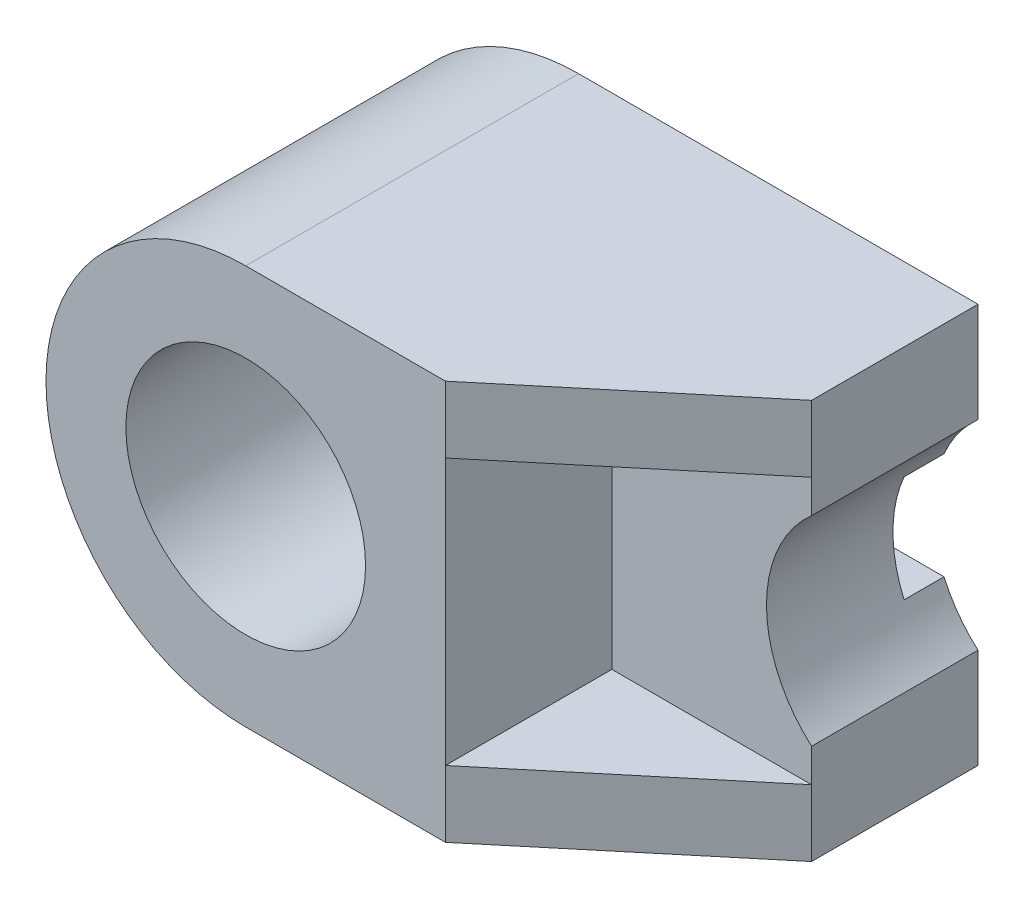
from build123d import *

# Parameters (mm, degrees)
SKETCH1_R           = 18
BOSS_EXTRUDE1_DEPTH = 50
BOSS_EXTRUDE3_DEPTH = 25
BOSS_EXTRUDE4_DEPTH = 10
BOSS_EXTRUDE5_DEPTH = 10
CUT_EXTRUDE2_START  = -6
CUT_EXTRUDE2_DEPTH  = 6
CUT_EXTRUDE3_DEPTH  = 6


with BuildPart() as part:
    # Sketch1 → Boss-Extrude1 (new body)
    with BuildSketch(Plane.XY):
        with BuildLine():
            Line((0, 30), (30, 30))
            Line((30, 30), (30, -30))
            Line((30, -30), (0, -30))
            ThreePointArc((0, -30), (-30, 0), (0, 30))
        make_face()
        Circle(SKETCH1_R, mode=Mode.SUBTRACT)
    extrude(amount=-BOSS_EXTRUDE1_DEPTH)

    # Sketch2 → Boss-Extrude3 (add)
    with BuildSketch(Plane(origin=(0, 0, -50), x_dir=(-1, 0, 0), z_dir=(0, 0, -1))):
        with BuildLine():
            Line((-60, -30), (-30, -30))
            Line((-30, -30), (-30, 30))
            Line((-30, 30), (-60, 30))
            Line((-60, 30), (-60, 15))
            ThreePointArc((-60, 15), (-53.228756555, 0), (-60, -15))
            Line((-60, -15), (-60, -30))
        make_face()
    extrude(amount=-BOSS_EXTRUDE3_DEPTH)

    # Sketch6 → Boss-Extrude4 (add)
    with BuildSketch(Plane(origin=(0, 30, 0), x_dir=(1, 0, 0), z_dir=(0, 1, 0))):
        Polygon((60, 25), (30, 0), (30, 25), align=None)
    extrude(amount=-BOSS_EXTRUDE4_DEPTH)

    # Sketch11 → Boss-Extrude5 (add)
    with BuildSketch(Plane(origin=(0, -30, 0), x_dir=(-1, 0, 0), z_dir=(0, -1, 0))):
        Polygon((-30, 0), (-30, 25), (-60, 25), align=None)
    extrude(amount=-BOSS_EXTRUDE5_DEPTH)

    # Sketch12 → Cut-Extrude2 (cut)
    with BuildSketch(Plane(origin=(0, 0, -50), x_dir=(-1, 0, 0), z_dir=(0, 0, -1)).offset(CUT_EXTRUDE2_START)):
        with BuildLine():
            Line((28.91366459, 8), (16.124515497, 8))
            ThreePointArc((16.124515497, 8), (-18, 0), (16.124515497, -8))
            Line((16.124515497, -8), (28.91366459, -8))
            ThreePointArc((28.91366459, -8), (30, 0), (28.91366459, 8))
        make_face()
    extrude(amount=CUT_EXTRUDE2_DEPTH, mode=Mode.SUBTRACT)

    # Sketch12_8 → Cut-Extrude3 (cut)
    with BuildSketch(Plane(origin=(0, 0, -50), x_dir=(-1, 0, 0), z_dir=(0, 0, -1))):
        with BuildLine():
            Line((-16.124515497, 8), (-54.898453775, 8))
            ThreePointArc((-54.898453775, 8), (-53.228756555, 0), (-54.898453775, -8))
            Line((-54.898453775, -8), (-16.124515497, -8))
            ThreePointArc((-16.124515497, -8), (-18, 0), (-16.124515497, 8))
        make_face()
    extrude(amount=-CUT_EXTRUDE3_DEPTH, mode=Mode.SUBTRACT)


solid = part.part
